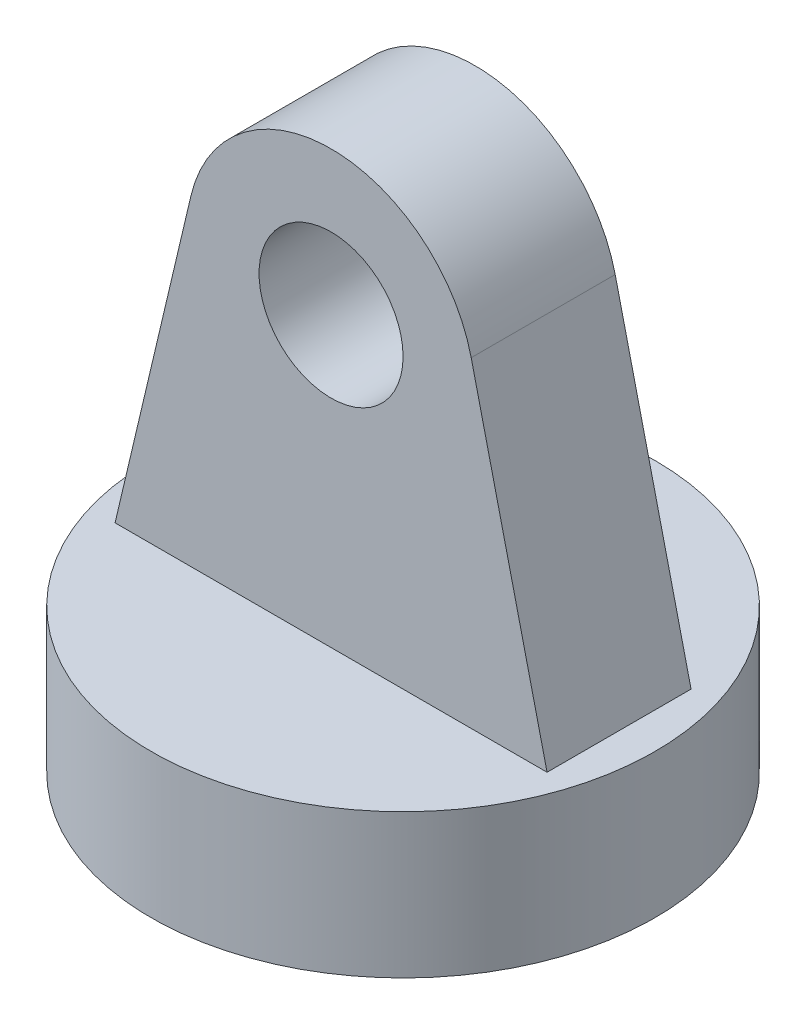
from build123d import *

# Parameters (mm, degrees)
SKETCH_1_R           = 5
EXTRUDE_1_DEPTH      = 10
EXTRUDE_2_DEPTH      = 5
EXTRUDE_2_DEPTH_BACK = 5
SKETCH_2_R           = 17.5


with BuildPart() as part:
    # 草图1 → 凸台-拉伸1 (new body)
    with BuildSketch(Plane.XY):
        with BuildLine():
            Line((-5.269515354, 307.463167958), (-10.537394242, 285.164077124))
            Line((-10.537394242, 285.164077124), (-10.537394242, 280.164077124))
            Line((-10.537394242, 280.164077124), (19.462605758, 280.164077124))
            Line((19.462605758, 280.164077124), (19.462605758, 285.164077124))
            Line((19.462605758, 285.164077124), (14.19472687, 307.463167958))
            ThreePointArc((14.19472687, 307.463167958), (4.462605758, 315.164077124), (-5.269515354, 307.463167958))
        make_face()
        with Locations((4.462605758, 305.164077124)):
            Circle(SKETCH_1_R, mode=Mode.SUBTRACT)
    extrude(amount=EXTRUDE_1_DEPTH)

    # 草图2 → 凸台-拉伸2 (add, two sides: drawn at the far end of the back side and taken through both)
    with BuildSketch(Plane.XZ.offset(-280.164077124).offset(-EXTRUDE_2_DEPTH_BACK)):
        with Locations((4.462605758, 5)):
            Circle(SKETCH_2_R)
    extrude(amount=EXTRUDE_2_DEPTH + EXTRUDE_2_DEPTH_BACK)


solid = part.part
